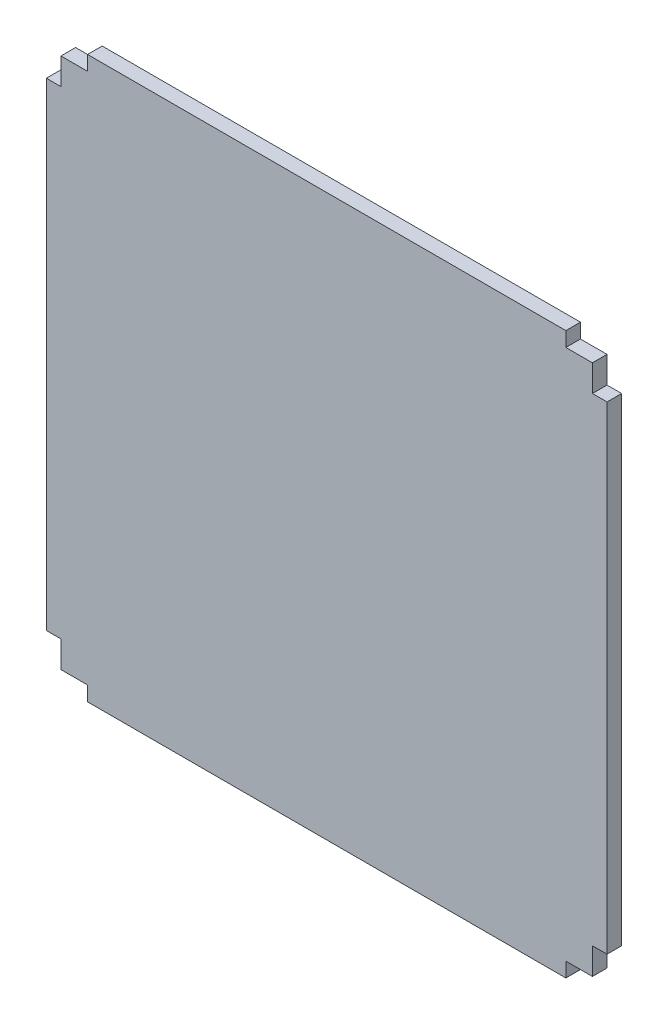
from build123d import *

# Parameters (mm, degrees)
SKETCH_1_W      = 2.75
SKETCH_1_H      = 90
SKETCH_1_W_2    = 90
SKETCH_1_H_2    = 2.75
EXTRUDE_1_DEPTH = 2.75


with BuildPart() as part:
    # 草图1 → 凸台-拉伸1 (new body)
    with BuildSketch(Plane.XY):
        Polygon((5, 100), (0, 100), (0, 95), (0, 5), (0, 0), (5, 0), (95, 0), (100, 0), (100, 5), (100, 95), (100, 100), (95, 100), align=None)
        with Locations((-1.375, 50)):
            Rectangle(SKETCH_1_W, SKETCH_1_H)
        with Locations((50, 101.375)):
            Rectangle(SKETCH_1_W_2, SKETCH_1_H_2)
        with Locations((101.375, 50)):
            Rectangle(SKETCH_1_W, SKETCH_1_H)
        with Locations((50, -1.375)):
            Rectangle(SKETCH_1_W_2, SKETCH_1_H_2)
    extrude(amount=EXTRUDE_1_DEPTH)


solid = part.part
